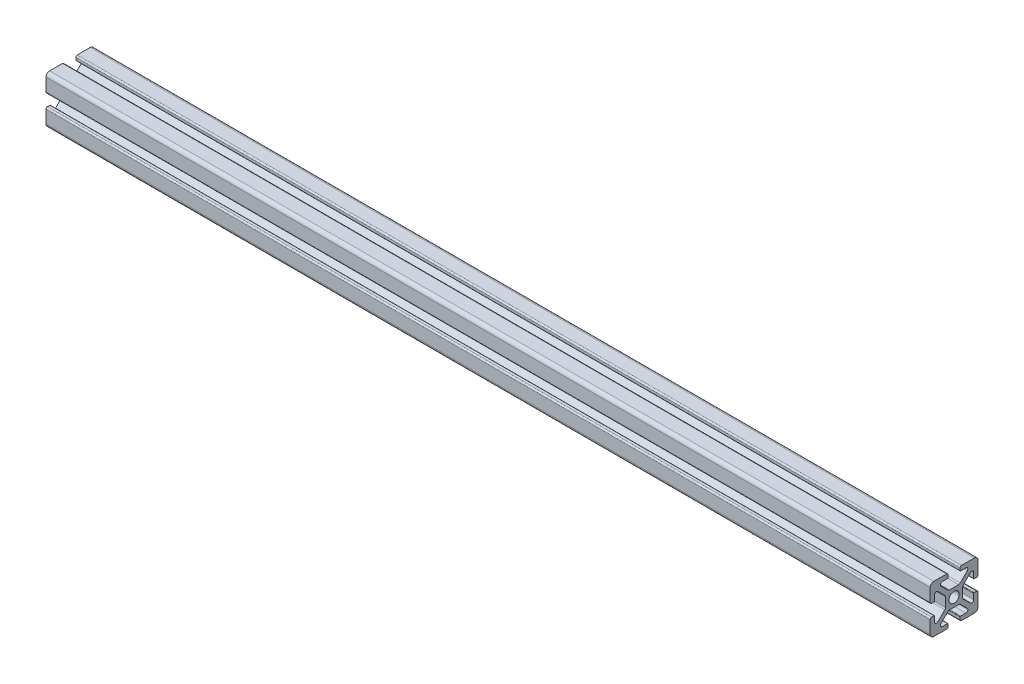
from build123d import *

# Parameters (mm, degrees)
BOSS_EXTRUDE1_DEPTH = 370


with BuildPart() as part:
    # Sketch3 → Boss-Extrude1 (new body)
    with BuildSketch(Plane(origin=(0, 0, 0), x_dir=(0, 0, -1), z_dir=(1, 0, 0))):
        with BuildLine():
            Line((-5.515685425, 6.807463915), (-2.601114729, 3.892893219))
            ThreePointArc((-2.601114729, 3.892893219), (-2.27669138, 3.676120467), (-1.894007948, 3.6))
            Line((-1.894007948, 3.6), (0, 3.6))
            Line((0, 3.6), (0, 2.15))
            ThreePointArc((0, 2.15), (-1.52027958, 1.52027958), (-2.15, 0))
            Line((-2.15, 0), (-3.6, 0))
            Line((-3.6, 0), (-3.6, 1.894007948))
            ThreePointArc((-3.6, 1.894007948), (-3.676120467, 2.27669138), (-3.892893219, 2.601114729))
            Line((-3.892893219, 2.601114729), (-6.807463915, 5.515685425))
            ThreePointArc((-6.807463915, 5.515685425), (-7.679296086, 5.689103626), (-8.17314934, 4.95))
            Line((-8.17314934, 4.95), (-8.17314934, 2.699999897))
            ThreePointArc((-8.17314934, 2.699999897), (-8.23172802, 2.558578607), (-8.37314934, 2.5))
            Line((-8.37314934, 2.5), (-9.4, 2.5))
            ThreePointArc((-9.4, 2.5), (-9.824264069, 2.675735931), (-10, 3.1))
            Line((-10, 3.1), (-10, 8.5))
            ThreePointArc((-10, 8.5), (-9.560660172, 9.560660172), (-8.5, 10))
            Line((-8.5, 10), (-3.1, 10))
            ThreePointArc((-3.1, 10), (-2.675735931, 9.824264069), (-2.5, 9.4))
            Line((-2.5, 9.4), (-2.5, 8.37314934))
            ThreePointArc((-2.5, 8.37314934), (-2.558578607, 8.23172802), (-2.699999897, 8.17314934))
            Line((-2.699999897, 8.17314934), (-4.95, 8.17314934))
            ThreePointArc((-4.95, 8.17314934), (-5.689103626, 7.679296086), (-5.515685425, 6.807463915))
        make_face()
    extrude(amount=-BOSS_EXTRUDE1_DEPTH)

    # Mirror1: part across plane


with BuildPart() as part_1:
    add(part.part)
    add(part.part.mirror(Plane.ZX))

    # Mirror2: part across plane


with BuildPart() as part_2:
    add(part_1.part)
    add(part_1.part.mirror(Plane.XY))


solid = part_2.part
